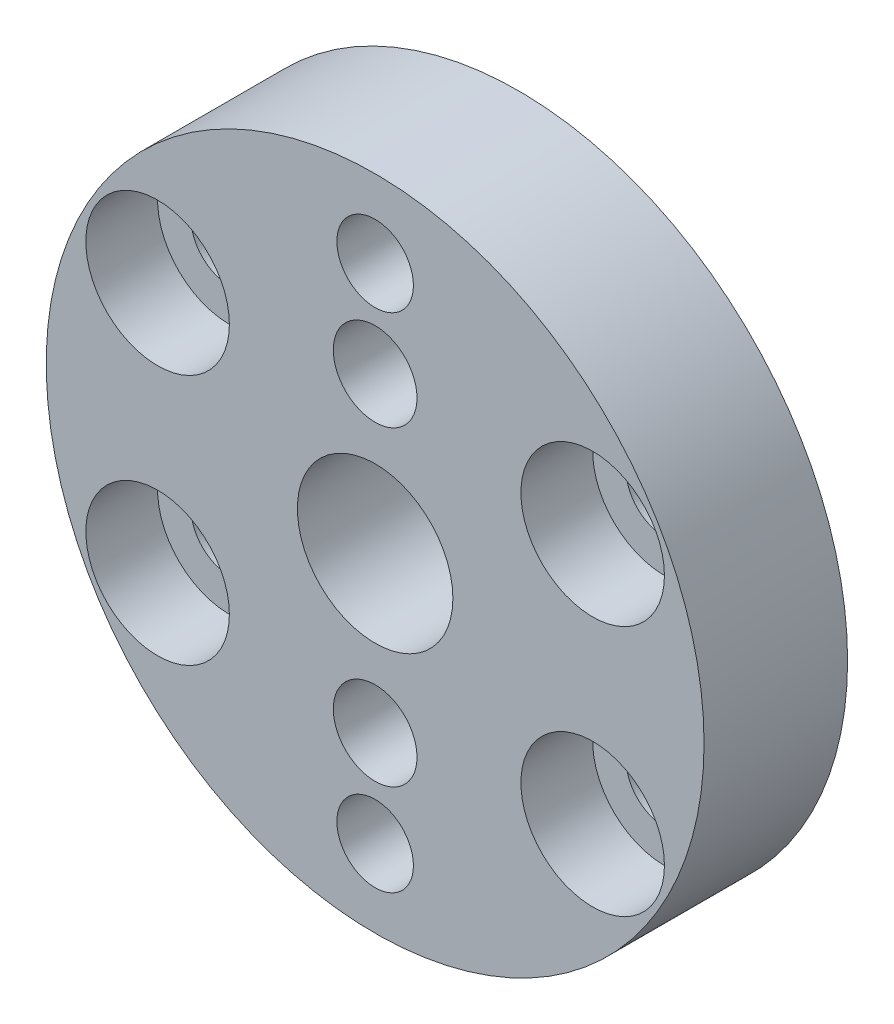
from build123d import *

# Parameters (mm, degrees)
SKETCH_1_R          = 13.75
SKETCH_1_R_2        = 1.6
SKETCH_1_R_3        = 3.25
EXTRUDE_1_DEPTH     = 6
SKETCH_2_R          = 1.75
CUT_EXTRUDE_1_DEPTH = 7
SKETCH_3_R          = 3
CUT_EXTRUDE_2_DEPTH = 3
CUT_EXTRUDE_6_DEPTH = 3


with BuildPart() as part:
    # ｽｹｯﾁ1 → ﾎﾞｽ - 押し出し1 (new body)
    with BuildSketch(Plane.XY):
        Circle(SKETCH_1_R)
        with Locations((0, 10.5)):
            Circle(SKETCH_1_R_2, mode=Mode.SUBTRACT)
        with Locations((9.09326674, 5.25)):
            Circle(SKETCH_1_R_2, mode=Mode.SUBTRACT)
        with Locations((9.09326674, -5.25)):
            Circle(SKETCH_1_R_2, mode=Mode.SUBTRACT)
        with Locations((0, -10.5)):
            Circle(SKETCH_1_R_2, mode=Mode.SUBTRACT)
        with Locations((-9.09326674, -5.25)):
            Circle(SKETCH_1_R_2, mode=Mode.SUBTRACT)
        with Locations((-9.09326674, 5.25)):
            Circle(SKETCH_1_R_2, mode=Mode.SUBTRACT)
        Circle(SKETCH_1_R_3, mode=Mode.SUBTRACT)
    extrude(amount=EXTRUDE_1_DEPTH)

    # ｽｹｯﾁ2 → ｶｯﾄ - 押し出し1 (cut, through all)
    with BuildSketch(Plane.XY.offset(6)):
        with Locations((0, 6.5)):
            Circle(SKETCH_2_R)
        with Locations((0, -6.5)):
            Circle(SKETCH_2_R)
    extrude(amount=-CUT_EXTRUDE_1_DEPTH, mode=Mode.SUBTRACT)

    # ｽｹｯﾁ3 → ｶｯﾄ - 押し出し2 (cut)
    with BuildSketch(Plane.XY.offset(6)):
        with Locations((9.09326674, 5.25)):
            Circle(SKETCH_3_R)
        with Locations((-9.09326674, -5.25)):
            Circle(SKETCH_3_R)
        with Locations((-9.09326674, 5.25)):
            Circle(SKETCH_3_R)
        with Locations((9.09326674, -5.25)):
            Circle(SKETCH_3_R)
    extrude(amount=-CUT_EXTRUDE_2_DEPTH, mode=Mode.SUBTRACT)

    # ｽｹｯﾁ7 → ｶｯﾄ - 押し出し6 (cut)
    with BuildSketch(Plane(origin=(0, 0, 0), x_dir=(-1, 0, 0), z_dir=(0, 0, -1))):
        Polygon((1.752709389, 3.512022457), (3.464019153, 6.523902085), (1.711309763, 9.511879628), (-1.752709389, 9.487977543), (-3.464019153, 6.476097915), (-1.711309763, 3.488120372), align=None)
        Polygon((2.335754412, -9.058173436), (3.383320389, -5.75626406), (1.047565977, -3.198090624), (-2.335754412, -3.941826564), (-3.383320389, -7.24373594), (-1.047565977, -9.801909376), align=None)
    extrude(amount=-CUT_EXTRUDE_6_DEPTH, mode=Mode.SUBTRACT)


solid = part.part
